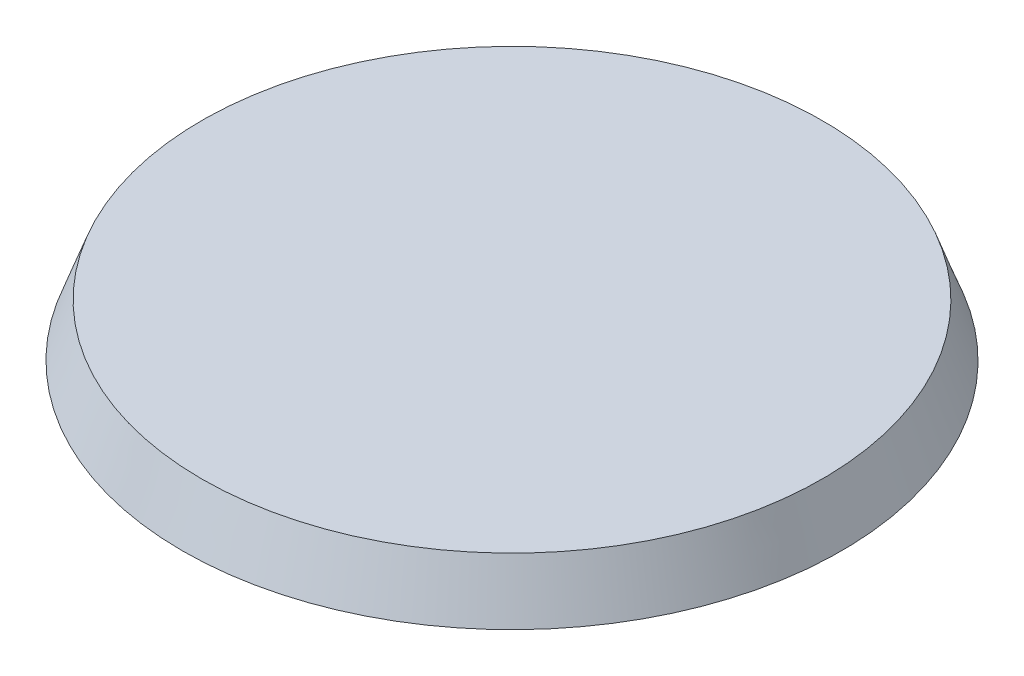
from build123d import *

# Parameters (mm, degrees)
SKETCH1_R           = 25
BOSS_EXTRUDE1_DEPTH = 4
BOSS_EXTRUDE1_TAPER = 20


with BuildPart() as part:
    # Sketch1 → Boss-Extrude1 (new body)
    with BuildSketch(Plane(origin=(0, 0, 0), x_dir=(1, 0, 0), z_dir=(0, 1, 0))):
        Circle(SKETCH1_R)
    extrude(amount=BOSS_EXTRUDE1_DEPTH, taper=BOSS_EXTRUDE1_TAPER)


solid = part.part
